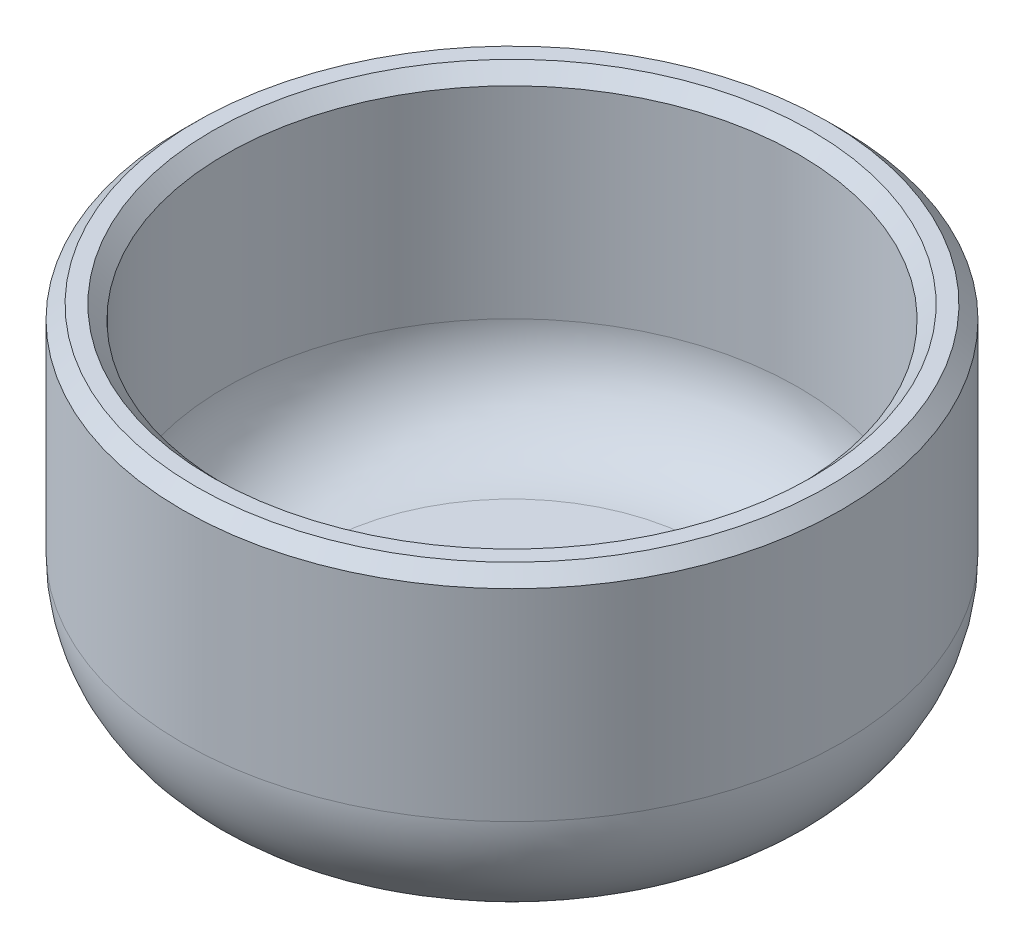
from build123d import *

# Parameters (mm, degrees)
SKIZZE1_R                       = 12.25
AUFSATZ_LINEAR_AUSTRAGEN1_DEPTH = 13
VERRUNDUNG1_R                   = 5
WANDUNG1_T                      = -1.6
FASE1_SIZE                      = 0.5


with BuildPart() as part:
    # Skizze1 → Aufsatz-Linear austragen1 (new body)
    with BuildSketch(Plane(origin=(0, 0, 0), x_dir=(1, 0, 0), z_dir=(0, 1, 0))):
        with Locations(Location((0, 0, 0), (0, 0, 90))):
            Circle(SKIZZE1_R)
    extrude(amount=AUFSATZ_LINEAR_AUSTRAGEN1_DEPTH)

    # Verrundung1
    verrundung1_edges = [part.edges().sort_by_distance(p)[0] for p in [
        (0, 0, 12.25),
    ]]
    fillet(verrundung1_edges, radius=VERRUNDUNG1_R)

    # Wandung1
    wandung1_openings = [part.faces().sort_by_distance(p)[0] for p in [
        (0, 13, 0),
    ]]
    offset(amount=WANDUNG1_T, openings=wandung1_openings, kind=Kind.INTERSECTION)

    # Fase1
    fase1_edges = [part.edges().sort_by_distance(p)[0] for p in [
        (0, 13, 12.25),
        (0, 13, 10.65),
    ]]
    chamfer(fase1_edges, length=FASE1_SIZE)


solid = part.part
